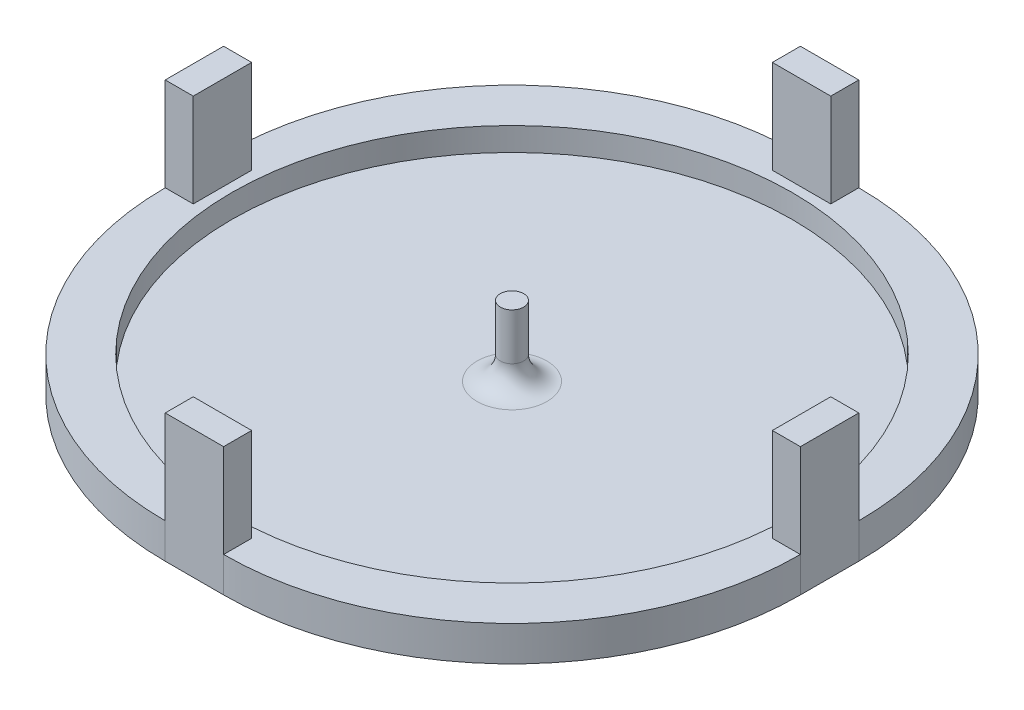
from build123d import *

# Parameters (mm, degrees)
SKETCH1_W             = 1.2
SKETCH1_H             = 2.5
BOSS_EXTRUDE1_DEPTH   = 5.5
SKETCH1_W_2           = 2.5
SKETCH1_H_2           = 1.2
BOSS_EXTRUDE1_2_DEPTH = 5.5
BOSS_EXTRUDE1_3_DEPTH = 5.5
BOSS_EXTRUDE1_4_DEPTH = 5.5
SKETCH1_4_W           = 2.5
SKETCH1_4_H           = 2.5
BOSS_EXTRUDE2_DEPTH   = 0.5
BOSS_EXTRUDE3_DEPTH   = 1.5
SKETCH2_R             = 0.5
BOSS_EXTRUDE4_DEPTH   = 3
FILLET1_R             = 1


with BuildPart() as part:
    # Sketch1 → Boss-Extrude1 (new body)
    with BuildSketch(Plane(origin=(0, 0, 0), x_dir=(1, 0, 0), z_dir=(0, 1, 0))):
        with Locations((-13, 0)):
            Rectangle(SKETCH1_W, SKETCH1_H)
    extrude(amount=BOSS_EXTRUDE1_DEPTH)



with BuildPart() as body_2:
    # Sketch1 → Boss-Extrude1 2 (new body)
    with BuildSketch(Plane(origin=(0, 0, 0), x_dir=(1, 0, 0), z_dir=(0, 1, 0))):
        with Locations((0, 13)):
            Rectangle(SKETCH1_W_2, SKETCH1_H_2)
    extrude(amount=BOSS_EXTRUDE1_2_DEPTH)


with BuildPart() as body_3:
    # Sketch1 → Boss-Extrude1 3 (new body)
    with BuildSketch(Plane(origin=(0, 0, 0), x_dir=(1, 0, 0), z_dir=(0, 1, 0))):
        with Locations((13, 0)):
            Rectangle(SKETCH1_W, SKETCH1_H)
    extrude(amount=BOSS_EXTRUDE1_3_DEPTH)


with BuildPart() as body_4:
    # Sketch1 → Boss-Extrude1 4 (new body)
    with BuildSketch(Plane(origin=(0, 0, 0), x_dir=(1, 0, 0), z_dir=(0, 1, 0))):
        with Locations((0, -13)):
            Rectangle(SKETCH1_W_2, SKETCH1_H_2)
    extrude(amount=BOSS_EXTRUDE1_4_DEPTH)


with BuildPart() as body_5:
    # Sketch1_4 → Boss-Extrude2 (new body)
    with BuildSketch(Plane(origin=(0, 0, 0), x_dir=(1, 0, 0), z_dir=(0, 1, 0))):
        with BuildLine():
            ThreePointArc((-1.25, 11.934718262), (-8.485281374, 8.485281374), (-11.934718262, 1.25))
            Line((-11.934718262, 1.25), (-1.25, 1.25))
            Line((-1.25, 1.25), (-1.25, 11.934718262))
        make_face()
        with BuildLine():
            Line((1.25, 11.934718262), (1.25, 1.25))
            Line((1.25, 1.25), (11.934718262, 1.25))
            ThreePointArc((11.934718262, 1.25), (8.485281374, 8.485281374), (1.25, 11.934718262))
        make_face()
        with BuildLine():
            Line((-1.25, 11.934718262), (-1.25, 1.25))
            Line((-1.25, 1.25), (1.25, 1.25))
            Line((1.25, 1.25), (1.25, 11.934718262))
            ThreePointArc((1.25, 11.934718262), (0, 12), (-1.25, 11.934718262))
        make_face()
        with BuildLine():
            ThreePointArc((-11.934718262, 1.25), (-12, 0), (-11.934718262, -1.25))
            Line((-11.934718262, -1.25), (-1.25, -1.25))
            Line((-1.25, -1.25), (-1.25, 1.25))
            Line((-1.25, 1.25), (-11.934718262, 1.25))
        make_face()
        Rectangle(SKETCH1_4_W, SKETCH1_4_H)
        with BuildLine():
            Line((1.25, 1.25), (1.25, -1.25))
            Line((1.25, -1.25), (11.934718262, -1.25))
            ThreePointArc((11.934718262, -1.25), (11.983668452, -0.625851761), (12, 0))
            ThreePointArc((12, 0), (11.983668452, 0.625851761), (11.934718262, 1.25))
            Line((11.934718262, 1.25), (1.25, 1.25))
        make_face()
        with BuildLine():
            Line((11.934718262, -1.25), (1.25, -1.25))
            Line((1.25, -1.25), (1.25, -11.934718262))
            ThreePointArc((1.25, -11.934718262), (8.485281374, -8.485281374), (11.934718262, -1.25))
        make_face()
        with BuildLine():
            Line((-1.25, -1.25), (-11.934718262, -1.25))
            ThreePointArc((-11.934718262, -1.25), (-8.485281374, -8.485281374), (-1.25, -11.934718262))
            Line((-1.25, -11.934718262), (-1.25, -1.25))
        make_face()
        with BuildLine():
            Line((1.25, -1.25), (-1.25, -1.25))
            Line((-1.25, -1.25), (-1.25, -11.934718262))
            ThreePointArc((-1.25, -11.934718262), (0, -12), (1.25, -11.934718262))
            Line((1.25, -11.934718262), (1.25, -1.25))
        make_face()
    extrude(amount=BOSS_EXTRUDE2_DEPTH)


with BuildPart() as part_1:
    add(part.part)

    add(body_2.part)  # Boss-Extrude3 merges body 2

    add(body_3.part)  # Boss-Extrude3 merges body 3

    add(body_4.part)  # Boss-Extrude3 merges body 4

    add(body_5.part)  # Boss-Extrude3 merges body 5
    # Sketch1_5 → Boss-Extrude3 (add)
    with BuildSketch(Plane(origin=(0, 0, 0), x_dir=(1, 0, 0), z_dir=(0, 1, 0))):
        with BuildLine():
            ThreePointArc((-1.25, 13.6), (-9.982768748, 9.982768748), (-13.6, 1.25))
            Line((-13.6, 1.25), (-12.4, 1.25))
            Line((-12.4, 1.25), (-11.934718262, 1.25))
            ThreePointArc((-11.934718262, 1.25), (-8.485281374, 8.485281374), (-1.25, 11.934718262))
            Line((-1.25, 11.934718262), (-1.25, 12.4))
            Line((-1.25, 12.4), (-1.25, 13.6))
        make_face()
        with BuildLine():
            ThreePointArc((13.6, 1.25), (9.982768748, 9.982768748), (1.25, 13.6))
            Line((1.25, 13.6), (1.25, 12.4))
            Line((1.25, 12.4), (1.25, 11.934718262))
            ThreePointArc((1.25, 11.934718262), (8.485281374, 8.485281374), (11.934718262, 1.25))
            Line((11.934718262, 1.25), (12.4, 1.25))
            Line((12.4, 1.25), (13.6, 1.25))
        make_face()
        with BuildLine():
            Line((1.25, 12.4), (-1.25, 12.4))
            Line((-1.25, 12.4), (-1.25, 11.934718262))
            ThreePointArc((-1.25, 11.934718262), (0, 12), (1.25, 11.934718262))
            Line((1.25, 11.934718262), (1.25, 12.4))
        make_face()
        with BuildLine():
            Line((1.25, -12.4), (1.25, -13.6))
            ThreePointArc((1.25, -13.6), (9.982768748, -9.982768748), (13.6, -1.25))
            Line((13.6, -1.25), (12.4, -1.25))
            Line((12.4, -1.25), (11.934718262, -1.25))
            ThreePointArc((11.934718262, -1.25), (8.485281374, -8.485281374), (1.25, -11.934718262))
            Line((1.25, -11.934718262), (1.25, -12.4))
        make_face()
        with BuildLine():
            Line((11.934718262, -1.25), (12.4, -1.25))
            Line((12.4, -1.25), (12.4, 1.25))
            Line((12.4, 1.25), (11.934718262, 1.25))
            ThreePointArc((11.934718262, 1.25), (11.983668452, 0.625851761), (12, 0))
            ThreePointArc((12, 0), (11.983668452, -0.625851761), (11.934718262, -1.25))
        make_face()
        with BuildLine():
            Line((-12.4, -1.25), (-13.6, -1.25))
            ThreePointArc((-13.6, -1.25), (-9.982768748, -9.982768748), (-1.25, -13.6))
            Line((-1.25, -13.6), (-1.25, -12.4))
            Line((-1.25, -12.4), (-1.25, -11.934718262))
            ThreePointArc((-1.25, -11.934718262), (-8.485281374, -8.485281374), (-11.934718262, -1.25))
            Line((-11.934718262, -1.25), (-12.4, -1.25))
        make_face()
        with BuildLine():
            Line((-12.4, 1.25), (-12.4, -1.25))
            Line((-12.4, -1.25), (-11.934718262, -1.25))
            ThreePointArc((-11.934718262, -1.25), (-12, 0), (-11.934718262, 1.25))
            Line((-11.934718262, 1.25), (-12.4, 1.25))
        make_face()
        with BuildLine():
            Line((-1.25, -11.934718262), (-1.25, -12.4))
            Line((-1.25, -12.4), (1.25, -12.4))
            Line((1.25, -12.4), (1.25, -11.934718262))
            ThreePointArc((1.25, -11.934718262), (0, -12), (-1.25, -11.934718262))
        make_face()
    extrude(amount=BOSS_EXTRUDE3_DEPTH)

    # Sketch2 → Boss-Extrude4 (add)
    with BuildSketch(Plane(origin=(0, 0.5, 0), x_dir=(1, 0, 0), z_dir=(0, 1, 0))):
        Circle(SKETCH2_R)
    extrude(amount=BOSS_EXTRUDE4_DEPTH)

    # Fillet1
    fillet1_edges = [part_1.edges().sort_by_distance(p)[0] for p in [
        (-0.5, 0.5, 0),
    ]]
    fillet(fillet1_edges, radius=FILLET1_R)


solid = part_1.part
